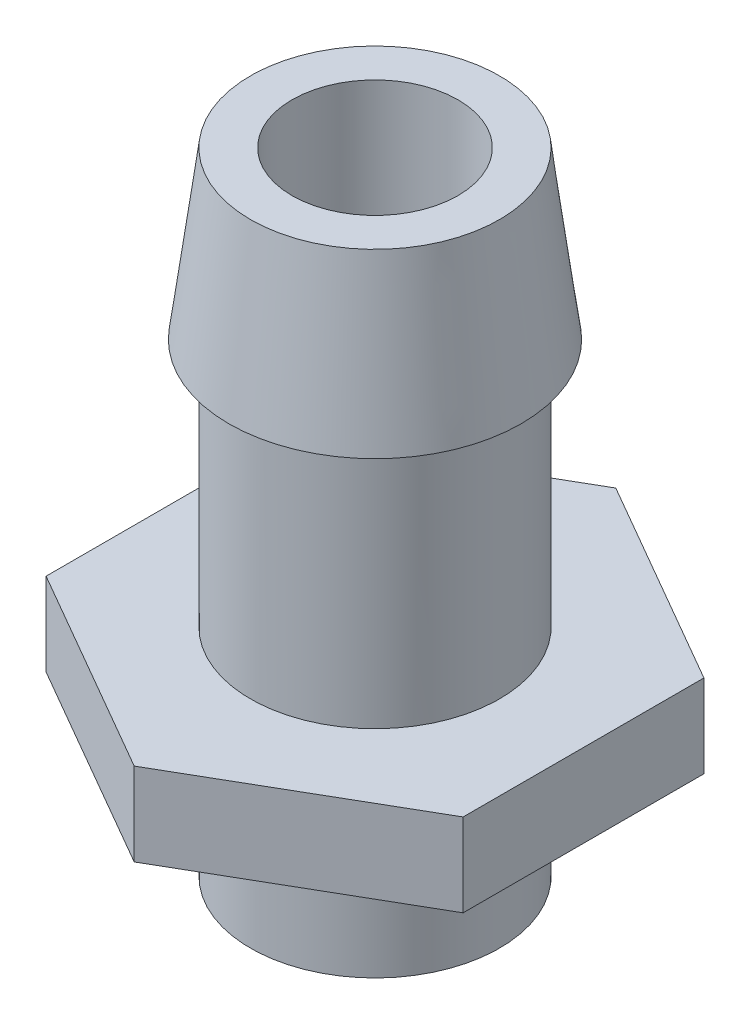
from build123d import *

# Parameters (mm, degrees)
SKETCH1_R          = 4.7625
SKETCH1_R_2        = 3.175
EXTRUDE1_DEPTH     = 15.875
SKETCH2_R          = 3.175
EXTRUDE2_DEPTH     = 3.175
SKETCH3_R          = 4.7625
SKETCH3_R_2        = 3.175
EXTRUDE3_DEPTH     = 5.08
SKETCH4_R          = 6.35
SKETCH4_R_2        = 4.7625
CUT_EXTRUDE1_DEPTH = 1.5875
SKETCH5_R          = 5.588
SKETCH5_R_2        = 4.7625
EXTRUDE4_DEPTH     = 6.35


with BuildPart() as part:
    # Sketch1 → Extrude1 (new body)
    with BuildSketch(Plane(origin=(0, 0, 0), x_dir=(1, 0, 0), z_dir=(0, 1, 0))):
        Circle(SKETCH1_R)
        Circle(SKETCH1_R_2, mode=Mode.SUBTRACT)
    extrude(amount=EXTRUDE1_DEPTH)

    # Sketch2 → Extrude2 (add)
    with BuildSketch(Plane.XZ):
        Polygon((7.973928905, 4.60375), (7.973928905, -4.60375), (0, -9.2075), (-7.973928905, -4.60375), (-7.973928905, 4.60375), (0, 9.2075), align=None)
        Circle(SKETCH2_R, mode=Mode.SUBTRACT)
    extrude(amount=EXTRUDE2_DEPTH)

    # Sketch3 → Extrude3 (add)
    with BuildSketch(Plane.XZ.offset(3.175)):
        Circle(SKETCH3_R)
        Circle(SKETCH3_R_2, mode=Mode.SUBTRACT)
    extrude(amount=EXTRUDE3_DEPTH)

    # Sketch4 → Cut-Extrude1 (cut)
    with BuildSketch(Plane.XZ.offset(3.175)):
        Circle(SKETCH4_R)
        Circle(SKETCH4_R_2, mode=Mode.SUBTRACT)
    extrude(amount=-CUT_EXTRUDE1_DEPTH, mode=Mode.SUBTRACT)

    # Sketch5 → Extrude4 (add)
    with BuildSketch(Plane(origin=(0, 15.875, 0), x_dir=(-1, 0, 0), z_dir=(0, 1, 0))):
        Circle(SKETCH5_R)
        Circle(SKETCH5_R_2, mode=Mode.SUBTRACT)
    extrude(amount=-EXTRUDE4_DEPTH)

    # Sketch7 → Cut-Revolve1 (revolve, cut)
    with BuildSketch(Plane(origin=(0, 0, 0), x_dir=(0, 0, -1), z_dir=(1, 0, 0))):
        Polygon((-5.588, 9.525), (-4.7625, 15.875), (-5.588, 15.875), align=None)
    revolve(axis=Axis((0, 15.875, 0), (0, -1, 0)), mode=Mode.SUBTRACT)


solid = part.part
